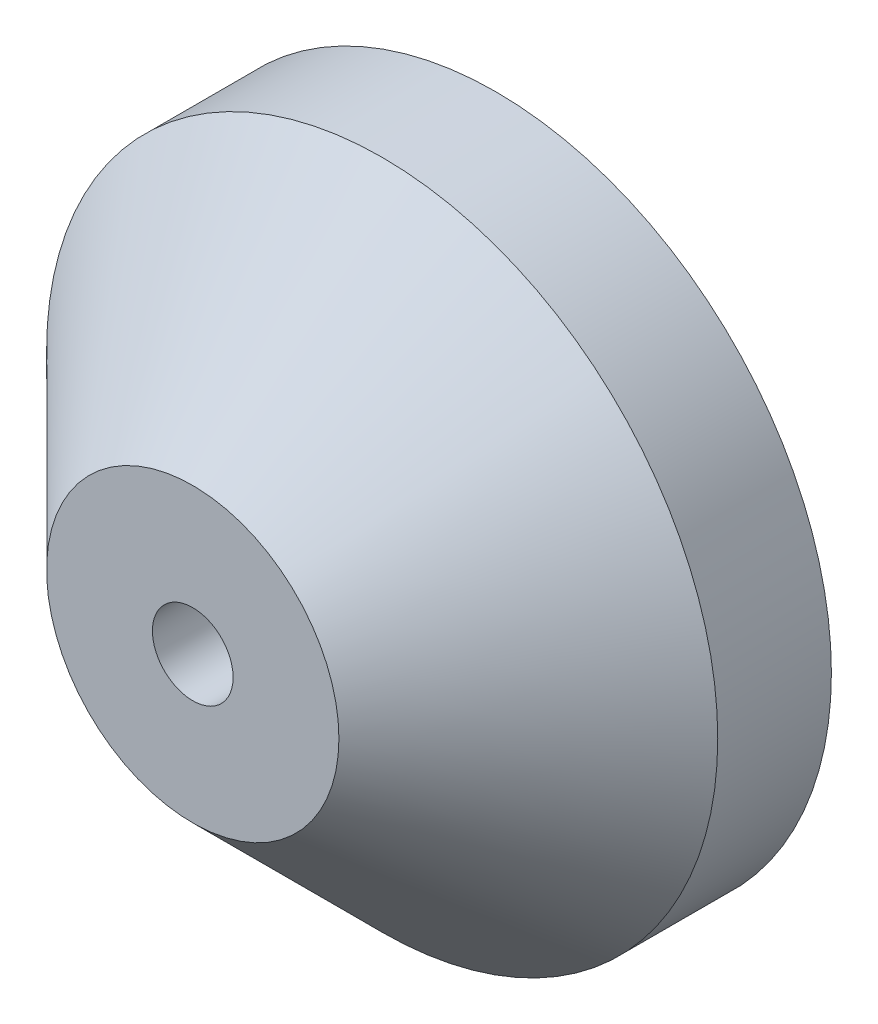
from build123d import *

# Parameters (mm, degrees)
SKETCH1_R                   = 22.5
BOSS_EXTRUDE1_DEPTH         = 20.32
SKETCH2_R                   = 17.5
CUT_EXTRUDE1_DEPTH          = 11
F_1_4_28_TAPPED_HOLE1_D     = 5.4102
F_1_4_28_TAPPED_HOLE1_DEPTH = 9.32
CHAMFER1_SIZE               = 12.7


with BuildPart() as part:
    # Sketch1 → Boss-Extrude1 (new body)
    with BuildSketch(Plane.XY):
        Circle(SKETCH1_R)
    extrude(amount=-BOSS_EXTRUDE1_DEPTH)

    # Sketch2 → Cut-Extrude1 (cut)
    with BuildSketch(Plane(origin=(0, 0, -20.32), x_dir=(-1, 0, 0), z_dir=(0, 0, -1))):
        Circle(SKETCH2_R)
    extrude(amount=-CUT_EXTRUDE1_DEPTH, mode=Mode.SUBTRACT)

    # 1/4-28 Tapped Hole1
    with Locations(Plane.XY):
        with Locations((0, 0)):
            Hole(F_1_4_28_TAPPED_HOLE1_D / 2, depth=F_1_4_28_TAPPED_HOLE1_DEPTH)

    # Chamfer1
    chamfer1_edges = [part.edges().sort_by_distance(p)[0] for p in [
        (-22.5, 0, 0),
    ]]
    chamfer(chamfer1_edges, length=CHAMFER1_SIZE)


solid = part.part
